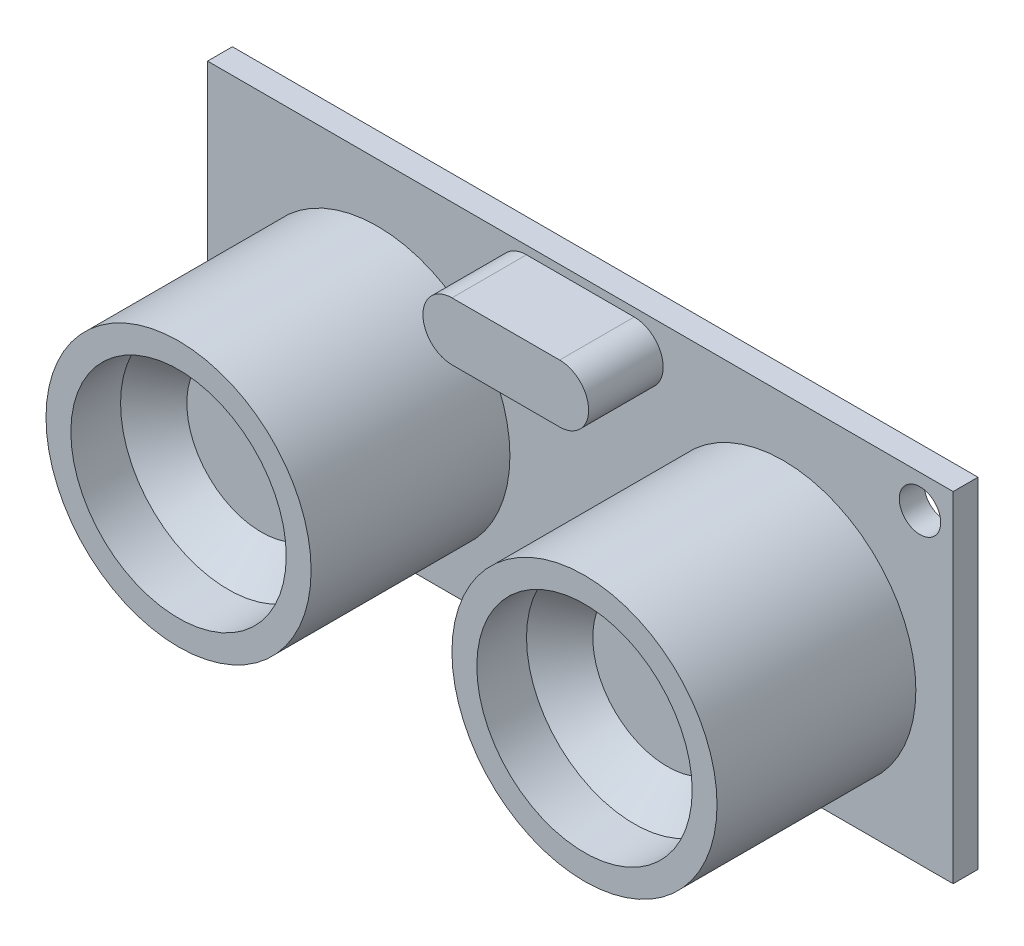
from build123d import *

# Parameters (mm, degrees)
SKETCH1_W                = 45
SKETCH1_H                = 20.5
SKETCH1_R                = 1.25
BOSS_EXTRUDE1_DEPTH      = 1.5
SKETCH2_R                = 8
BOSS_EXTRUDE2_DEPTH      = 12
BOSS_EXTRUDE3_DEPTH      = 4.5
SKETCH4_R                = 6.5
CUT_EXTRUDE2_DEPTH       = 5
CHAMFER1_SIZE            = 2
CHAMFER1_OF_MIRROR1_SIZE = 2
SKETCH5_W                = 13
SKETCH5_H                = 2.5
BOSS_EXTRUDE4_DEPTH      = 2.5
SKETCH7_W                = 0.5
SKETCH7_H                = 0.5
LPATTERN1_COUNT          = 3
LPATTERN1_PITCH          = 2.5
LPATTERN1_COL_COUNT      = 3
LPATTERN1_COL_PITCH      = 2.5


with BuildPart() as part:
    # Sketch1 → Boss-Extrude1 (new body)
    with BuildSketch(Plane.XY):
        Rectangle(SKETCH1_W, SKETCH1_H)
        with Locations((20.5, 8.25)):
            Circle(SKETCH1_R, mode=Mode.SUBTRACT)
        with Locations((-20.5, -8.25)):
            Circle(SKETCH1_R, mode=Mode.SUBTRACT)
    extrude(amount=BOSS_EXTRUDE1_DEPTH)

    # Sketch2 → Boss-Extrude2 (add)
    with BuildSketch(Plane.XY.offset(1.5)):
        with Locations((-12.25, -1.25)):
            Circle(SKETCH2_R)
        with Locations((12.25, -1.25)):
            Circle(SKETCH2_R)
    extrude(amount=BOSS_EXTRUDE2_DEPTH)

    # Sketch3 → Boss-Extrude3 (add)
    with BuildSketch(Plane.XY.offset(1.5)):
        with BuildLine():
            Line((-3.25, 9.75), (3.25, 9.75))
            ThreePointArc((3.25, 9.75), (5, 8), (3.25, 6.25))
            Line((3.25, 6.25), (-3.25, 6.25))
            ThreePointArc((-3.25, 6.25), (-5, 8), (-3.25, 9.75))
        make_face()
    extrude(amount=BOSS_EXTRUDE3_DEPTH)

    # Sketch4 → Cut-Extrude2 (cut)
    with BuildSketch(Plane.XY.offset(13.5)):
        with Locations((-12.25, -1.25)):
            Circle(SKETCH4_R)
    cut_extrude2 = extrude(amount=-CUT_EXTRUDE2_DEPTH, mode=Mode.SUBTRACT)

    # Chamfer1
    chamfer1_edges = [part.edges().sort_by_distance(p)[0] for p in [
        (-18.75, -1.25, 8.5),
    ]]
    chamfer(chamfer1_edges, length=CHAMFER1_SIZE)

    # Mirror1: Cut-Extrude2 across plane
    add(cut_extrude2.mirror(Plane(origin=(0, 0, 0), x_dir=(0, 0, 1), z_dir=(1, 0, 0))), mode=Mode.SUBTRACT)

    # Chamfer1 of Mirror1
    chamfer1_of_mirror1_edges = [part.edges().sort_by_distance(p)[0] for p in [
        (18.75, -1.25, 8.5),
    ]]
    chamfer(chamfer1_of_mirror1_edges, length=CHAMFER1_OF_MIRROR1_SIZE)


with BuildPart() as body_2:
    # Sketch5 → Boss-Extrude4 (new body)
    with BuildSketch(Plane(origin=(0, 0, 0), x_dir=(-1, 0, 0), z_dir=(0, 0, -1))):
        with Locations((0, -9)):
            Rectangle(SKETCH5_W, SKETCH5_H)
    extrude(amount=BOSS_EXTRUDE4_DEPTH)

    # Sweep1: sweep along a path in Sketch6
    with BuildLine(Plane(origin=(0, 0, 0), x_dir=(0, 0, -1), z_dir=(1, 0, 0))) as sweep1_path:
        Line((2.5, -9), (3.5, -9))
        ThreePointArc((3.5, -9), (3.853553391, -9.146446609), (4, -9.5))
        Line((4, -9.5), (4, -16.5))
    # Sketch7 → Sweep1 (sweep)
    with BuildSketch(Plane(origin=(0, 0, -2.5), x_dir=(-1, 0, 0), z_dir=(0, 0, -1))):
        with Locations((0, -9)):
            Rectangle(SKETCH7_W, SKETCH7_H)
    sweep1 = sweep(path=sweep1_path.line)

    # LPattern1: Sweep1 ×3
    with Locations(*[(-i * LPATTERN1_PITCH, 0, 0) for i in range(1, LPATTERN1_COUNT)]):
        add(sweep1)

    # LPattern1 col: Sweep1 ×3
    with Locations(*[(i * LPATTERN1_COL_PITCH, 0, 0) for i in range(1, LPATTERN1_COL_COUNT)]):
        add(sweep1)


solid = Compound([part.part, body_2.part])
